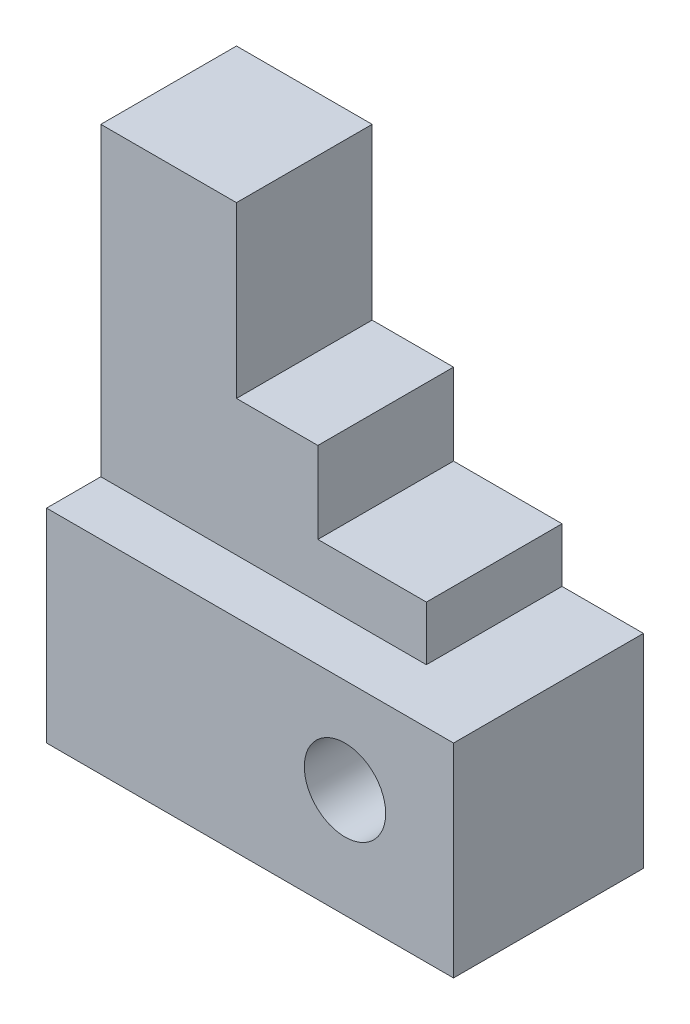
from build123d import *

# Parameters (mm, degrees)
SKETCH1_W           = 60
SKETCH1_H           = 28
BOSS_EXTRUDE1_DEPTH = 30
BOSS_EXTRUDE3_DEPTH = 20
SKETCH4_R           = 6
CUT_EXTRUDE1_DEPTH  = 29


with BuildPart() as part:
    # Sketch1 → Boss-Extrude1 (new body)
    with BuildSketch(Plane(origin=(0, 0, 0), x_dir=(1, 0, 0), z_dir=(0, 1, 0))):
        with Locations((30, 14)):
            Rectangle(SKETCH1_W, SKETCH1_H)
    extrude(amount=BOSS_EXTRUDE1_DEPTH)

    # Sketch3 → Boss-Extrude3 (add)
    with BuildSketch(Plane(origin=(0, 0, -28), x_dir=(-1, 0, 0), z_dir=(0, 0, -1))):
        Polygon((0, 30), (0, 75), (-20, 75), (-20, 50), (-32, 50), (-32, 38), (-48, 38), (-48, 30), align=None)
    extrude(amount=-BOSS_EXTRUDE3_DEPTH)

    # Sketch4 → Cut-Extrude1 (cut, through all)
    with BuildSketch(Plane.XY):
        with Locations((44, 16)):
            Circle(SKETCH4_R)
    extrude(amount=-CUT_EXTRUDE1_DEPTH, mode=Mode.SUBTRACT)


solid = part.part
